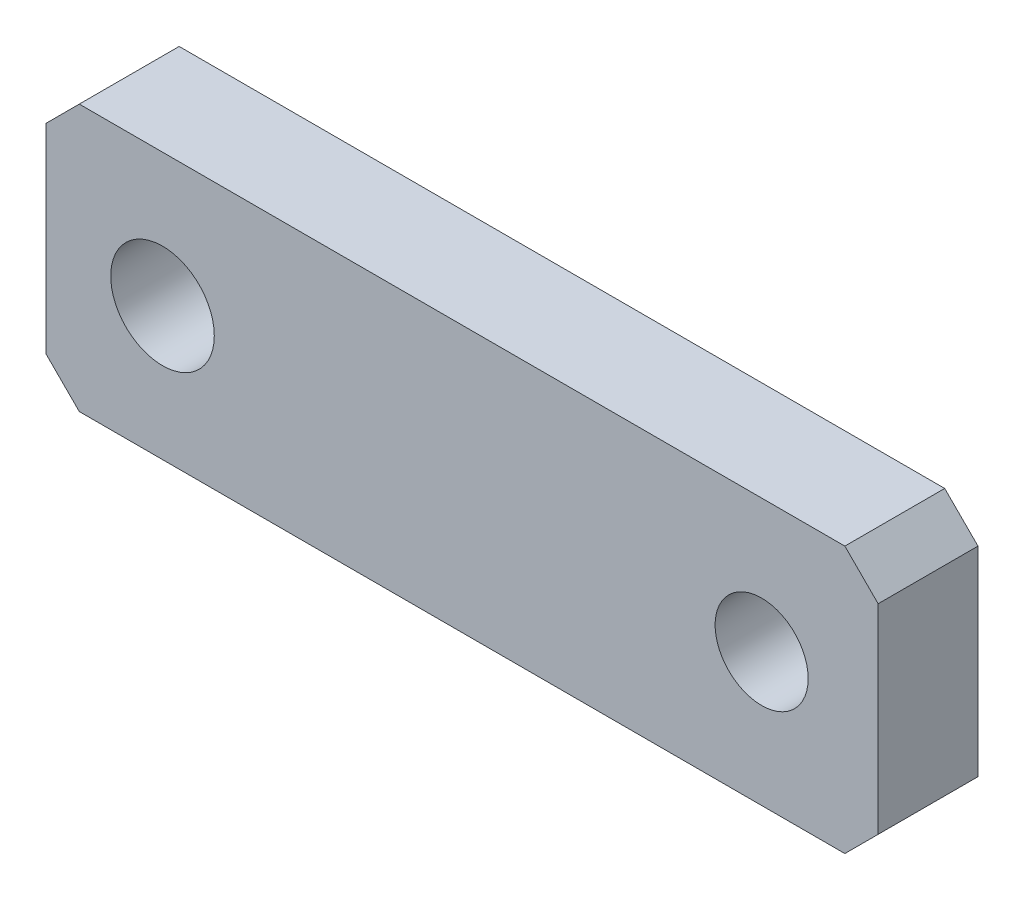
from build123d import *

# Parameters (mm, degrees)
SKETCH1_W           = 50
SKETCH1_H           = 16
SKETCH1_R           = 3.112420157
SKETCH1_R_2         = 2.795165179
BOSS_EXTRUDE1_DEPTH = 6
CHAMFER1_SIZE       = 2


with BuildPart() as part:
    # Sketch1 → Boss-Extrude1 (new body)
    with BuildSketch(Plane.XY):
        Rectangle(SKETCH1_W, SKETCH1_H)
        with Locations((-18, 0)):
            Circle(SKETCH1_R, mode=Mode.SUBTRACT)
        with Locations((18, 0)):
            Circle(SKETCH1_R_2, mode=Mode.SUBTRACT)
    extrude(amount=BOSS_EXTRUDE1_DEPTH)

    # Chamfer1
    chamfer1_edges = [part.edges().sort_by_distance(p)[0] for p in [
        (25, -8, 3),
        (-25, -8, 3),
        (-25, 8, 3),
        (25, 8, 3),
    ]]
    chamfer(chamfer1_edges, length=CHAMFER1_SIZE)


solid = part.part
